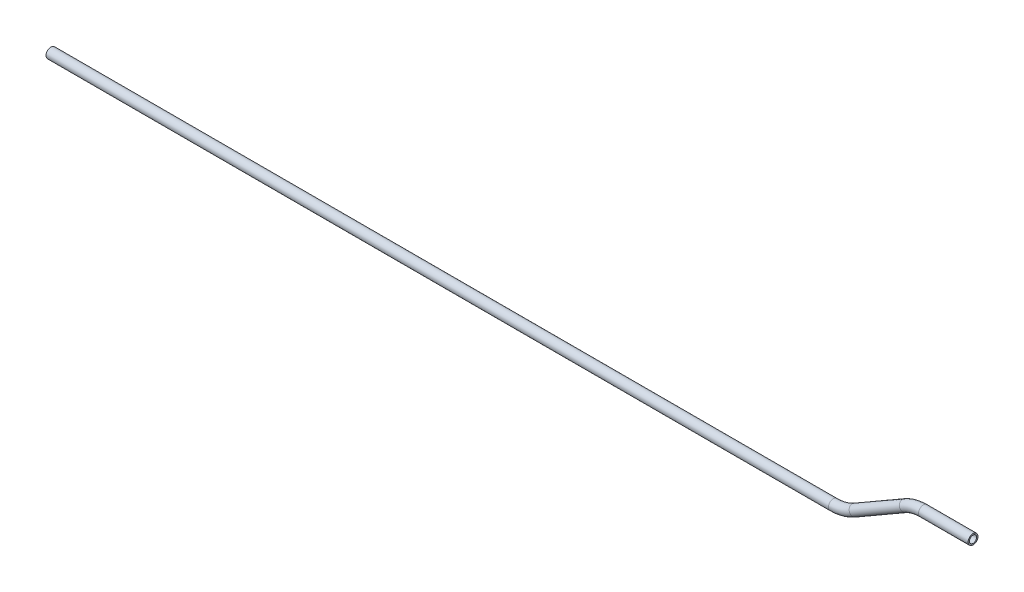
from build123d import *

# Parameters (mm, degrees)
SKETCH2_R   = 3.175
SKETCH2_R_2 = 2.286


with BuildPart() as part:
    # Sweep1: sweep along a path in Sketch1
    with BuildLine(Plane.XY) as sweep1_path:
        Line((31.760002734, 0), (0, 0))
        ThreePointArc((0, 0), (-6.123967098, -0.806235564), (-11.830595958, -3.169998633))
        Line((-11.830595958, -3.169998633), (-43.979259883, -21.731038404))
        ThreePointArc((-43.979259883, -21.731038404), (-50.584121448, -24.466861642), (-57.67201097, -25.4))
        Line((-57.67201097, -25.4), (-558.334087778, -25.4))
    # Sketch2 → Sweep1 (sweep)
    with BuildSketch(Plane(origin=(31.760002734, 0, 0), x_dir=(0, 0, -1), z_dir=(1, 0, 0))):
        Circle(SKETCH2_R)
        Circle(SKETCH2_R_2, mode=Mode.SUBTRACT)
    sweep(path=sweep1_path.line)


solid = part.part
